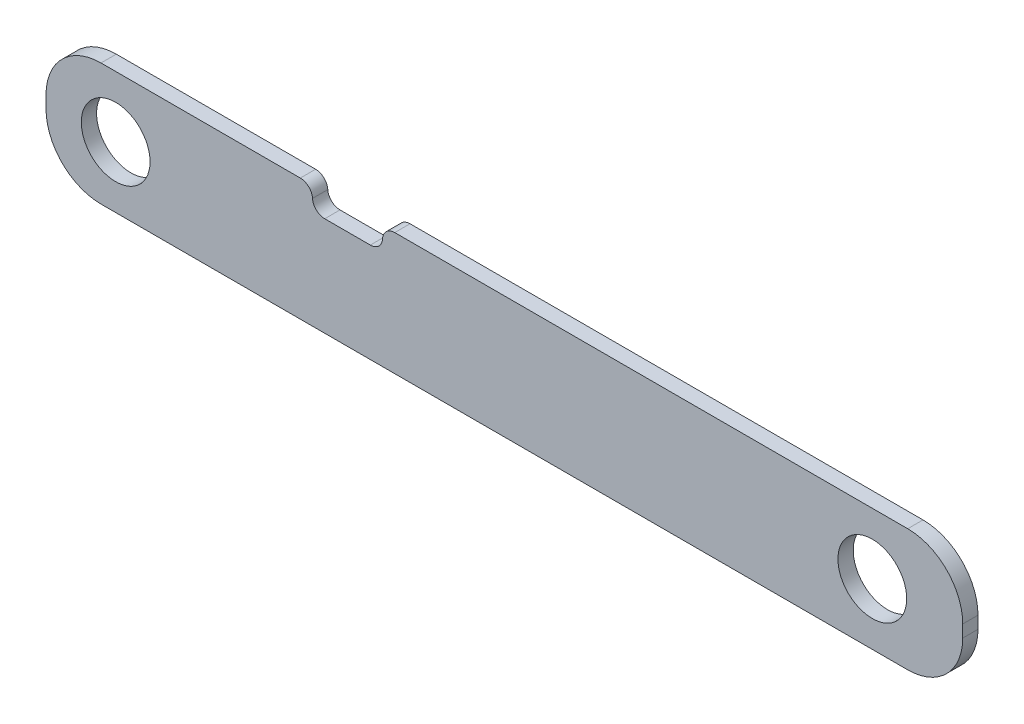
from build123d import *

# Parameters (mm, degrees)
SKETCH2_W           = 381
SKETCH2_H           = 50.8
BOSS_EXTRUDE1_DEPTH = 6.35
SKETCH3_R           = 14.2875
SKETCH3_W           = 29.084677523
SKETCH3_H           = 9.575779023
CUT_EXTRUDE1_DEPTH  = 6.35
FILLET4_R           = 22.86
FILLET5_R           = 22.86
FILLET6_R           = 22.86
FILLET7_R           = 22.86
FILLET12_R          = 5.08
FILLET13_R          = 5.08
FILLET14_R          = 5.08
FILLET15_R          = 5.08


with BuildPart() as part:
    # Sketch2 → Boss-Extrude1 (new body)
    with BuildSketch(Plane.XY):
        with Locations((-46.726415094, 80.033962264)):
            Rectangle(SKETCH2_W, SKETCH2_H)
    extrude(amount=BOSS_EXTRUDE1_DEPTH)

    # Sketch3 → Cut-Extrude1 (cut)
    with BuildSketch(Plane.XY.offset(6.35)):
        with Locations((-208.27071376, 80.033962264)):
            Circle(SKETCH3_R)
        with Locations((106.195061698, 80.033962264)):
            Circle(SKETCH3_R)
        with Locations((-111.901475121, 100.646072753)):
            Rectangle(SKETCH3_W, SKETCH3_H)
    extrude(amount=-CUT_EXTRUDE1_DEPTH, mode=Mode.SUBTRACT)

    # Fillet4
    fillet4_edges = [part.edges().sort_by_distance(p)[0] for p in [
        (143.773584906, 105.433962264, 3.175),
    ]]
    fillet(fillet4_edges, radius=FILLET4_R)

    # Fillet5
    fillet5_edges = [part.edges().sort_by_distance(p)[0] for p in [
        (143.773584906, 54.633962264, 3.175),
    ]]
    fillet(fillet5_edges, radius=FILLET5_R)

    # Fillet6
    fillet6_edges = [part.edges().sort_by_distance(p)[0] for p in [
        (-237.226415094, 54.633962264, 3.175),
    ]]
    fillet(fillet6_edges, radius=FILLET6_R)

    # Fillet7
    fillet7_edges = [part.edges().sort_by_distance(p)[0] for p in [
        (-237.226415094, 105.433962264, 3.175),
    ]]
    fillet(fillet7_edges, radius=FILLET7_R)

    # Fillet12
    fillet12_edges = [part.edges().sort_by_distance(p)[0] for p in [
        (-126.443813883, 105.433962264, 3.175),
    ]]
    fillet(fillet12_edges, radius=FILLET12_R)

    # Fillet13
    fillet13_edges = [part.edges().sort_by_distance(p)[0] for p in [
        (-97.35913636, 105.433962264, 3.175),
    ]]
    fillet(fillet13_edges, radius=FILLET13_R)

    # Fillet14
    fillet14_edges = [part.edges().sort_by_distance(p)[0] for p in [
        (-126.443813883, 95.858183241, 3.175),
    ]]
    fillet(fillet14_edges, radius=FILLET14_R)

    # Fillet15
    fillet15_edges = [part.edges().sort_by_distance(p)[0] for p in [
        (-97.35913636, 95.858183241, 3.175),
    ]]
    fillet(fillet15_edges, radius=FILLET15_R)


solid = part.part
